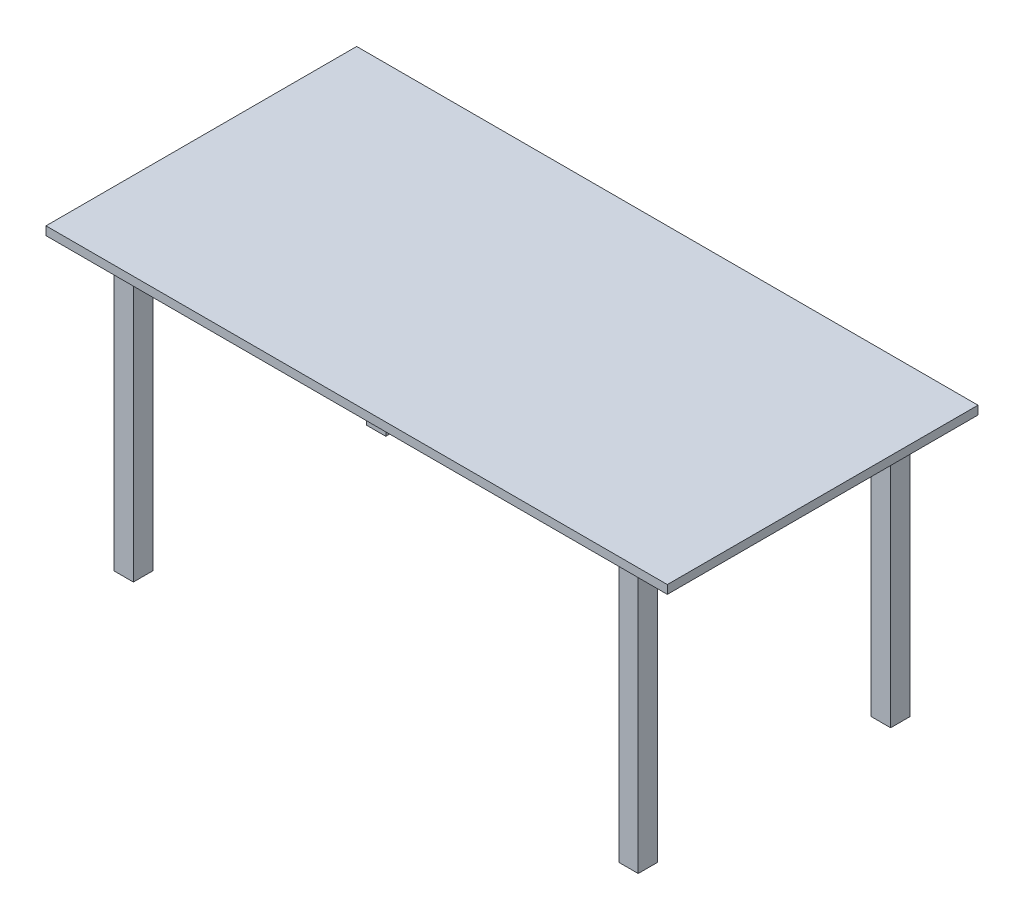
from build123d import *

# Parameters (mm, degrees)
SKETCH1_W           = 1600
SKETCH1_H           = 800
BOSS_EXTRUDE1_DEPTH = 22
SKETCH2_W           = 50
SKETCH2_H           = 50
BOSS_EXTRUDE2_DEPTH = 710


with BuildPart() as part:
    # Sketch1 → Boss-Extrude1 (new body)
    with BuildSketch(Plane(origin=(0, 0, 0), x_dir=(1, 0, 0), z_dir=(0, 1, 0))):
        Rectangle(SKETCH1_W, SKETCH1_H)
    extrude(amount=BOSS_EXTRUDE1_DEPTH)

    # Sketch2 → Boss-Extrude2 (add)
    with BuildSketch(Plane.XZ):
        with Locations((650, 325)):
            Rectangle(SKETCH2_W, SKETCH2_H)
        with Locations((-650, 325)):
            Rectangle(SKETCH2_W, SKETCH2_H)
        with Locations((-650, -325)):
            Rectangle(SKETCH2_W, SKETCH2_H)
        with Locations((650, -325)):
            Rectangle(SKETCH2_W, SKETCH2_H)
    extrude(amount=BOSS_EXTRUDE2_DEPTH)


solid = part.part
